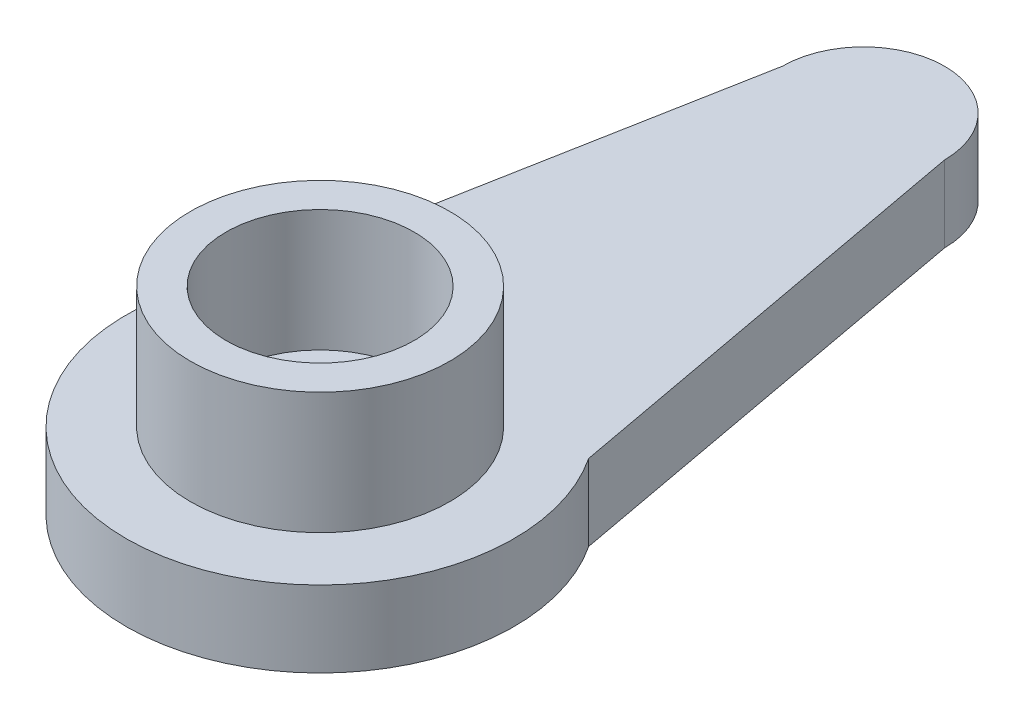
from build123d import *

# Parameters (mm, degrees)
SKETCH1_R           = 1.55
BOSS_EXTRUDE1_DEPTH = 2.35
SKETCH1_3_R         = 4
SKETCH1_3_R_2       = 2.9
BOSS_EXTRUDE2_DEPTH = 6.1


with BuildPart() as part:
    # Sketch1 → Boss-Extrude1 (new body)
    with BuildSketch(Plane(origin=(0, 0, 0), x_dir=(1, 0, 0), z_dir=(0, 1, 0))):
        with BuildLine():
            ThreePointArc((2.5, 16.75), (0, 19.25), (-2.5, 16.75))
            Line((-2.5, 16.75), (-5.015451004, 3.247441489))
            ThreePointArc((-5.015451004, 3.247441489), (0.028324767, -5.974932862), (4.984436631, 3.294846957))
            Line((4.984436631, 3.294846957), (2.5, 16.75))
        make_face()
        Circle(SKETCH1_R, mode=Mode.SUBTRACT)
    extrude(amount=BOSS_EXTRUDE1_DEPTH)

    # Sketch1_3 → Boss-Extrude2 (add)
    with BuildSketch(Plane(origin=(0, 0, 0), x_dir=(1, 0, 0), z_dir=(0, 1, 0))):
        Circle(SKETCH1_3_R)
        Circle(SKETCH1_3_R_2, mode=Mode.SUBTRACT)
    extrude(amount=BOSS_EXTRUDE2_DEPTH)


solid = part.part
